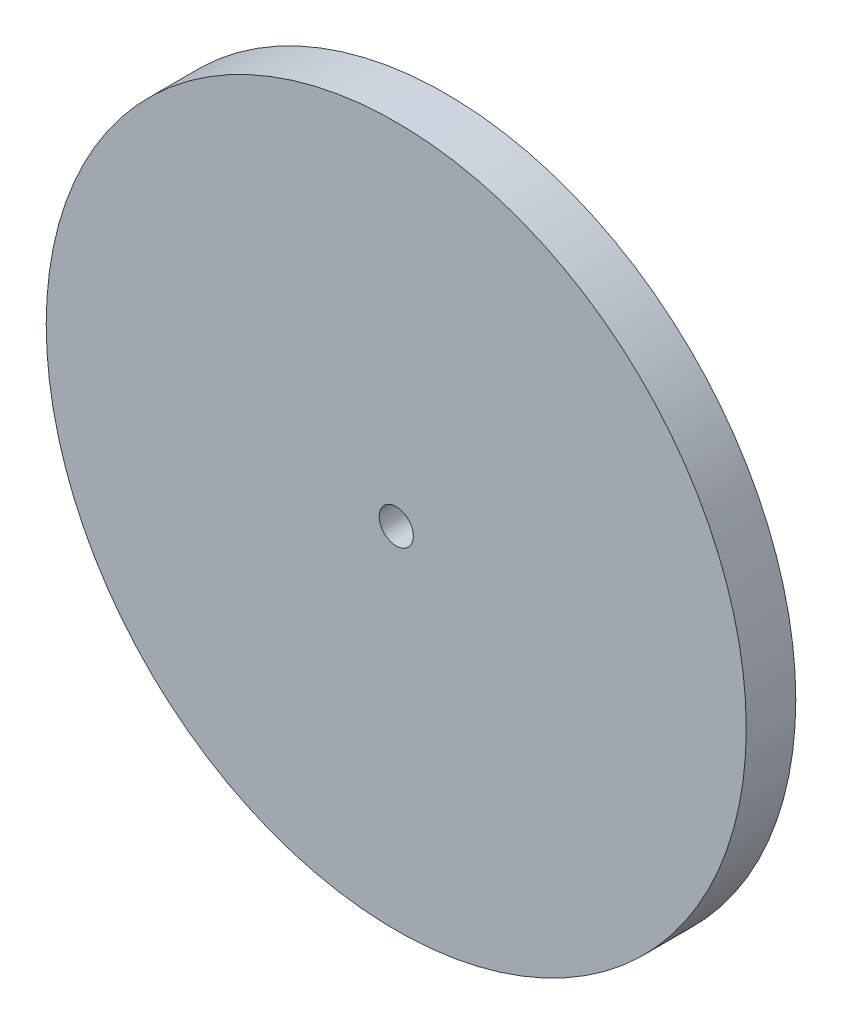
from build123d import *

# Parameters (mm, degrees)
SKETCH1_R           = 41
SKETCH1_R_2         = 2
BOSS_EXTRUDE1_DEPTH = 5.8


with BuildPart() as part:
    # Sketch1 → Boss-Extrude1 (new body)
    with BuildSketch(Plane.XY):
        Circle(SKETCH1_R)
        Circle(SKETCH1_R_2, mode=Mode.SUBTRACT)
    extrude(amount=BOSS_EXTRUDE1_DEPTH)


solid = part.part
